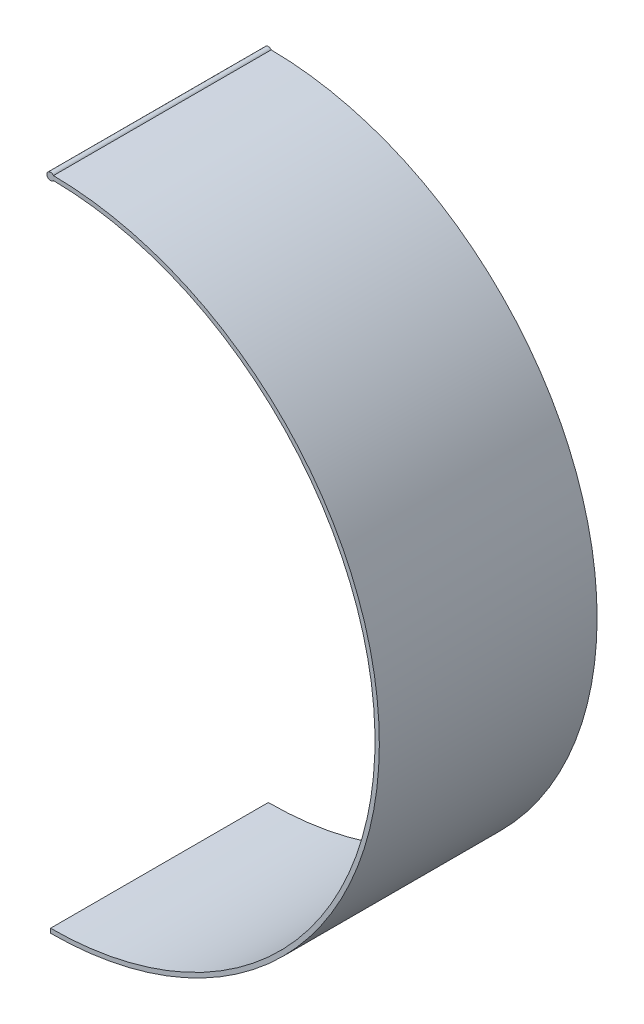
from build123d import *

# Parameters (mm, degrees)
SKETCH_1_R      = 0.25
EXTRUDE_1_DEPTH = 15
EXTRUDE_2_DEPTH = 15


with BuildPart() as part:
    # ｽｹｯﾁ1 → ﾎﾞｽ - 押し出し1 (new body)
    with BuildSketch(Plane.XY):
        Circle(SKETCH_1_R)
    extrude(amount=EXTRUDE_1_DEPTH)

    # ｽｹｯﾁ2 → ﾎﾞｽ - 押し出し2 (add)
    with BuildSketch(Plane.XY.offset(15)):
        with BuildLine():
            Line((0, -44.85), (0, -45.15))
            ThreePointArc((0, -45.15), (22.65, -22.5), (0, 0.15))
            Line((0, 0.15), (0, -0.15))
            ThreePointArc((0, -0.15), (22.35, -22.5), (0, -44.85))
        make_face()
    extrude(amount=-EXTRUDE_2_DEPTH)


solid = part.part
